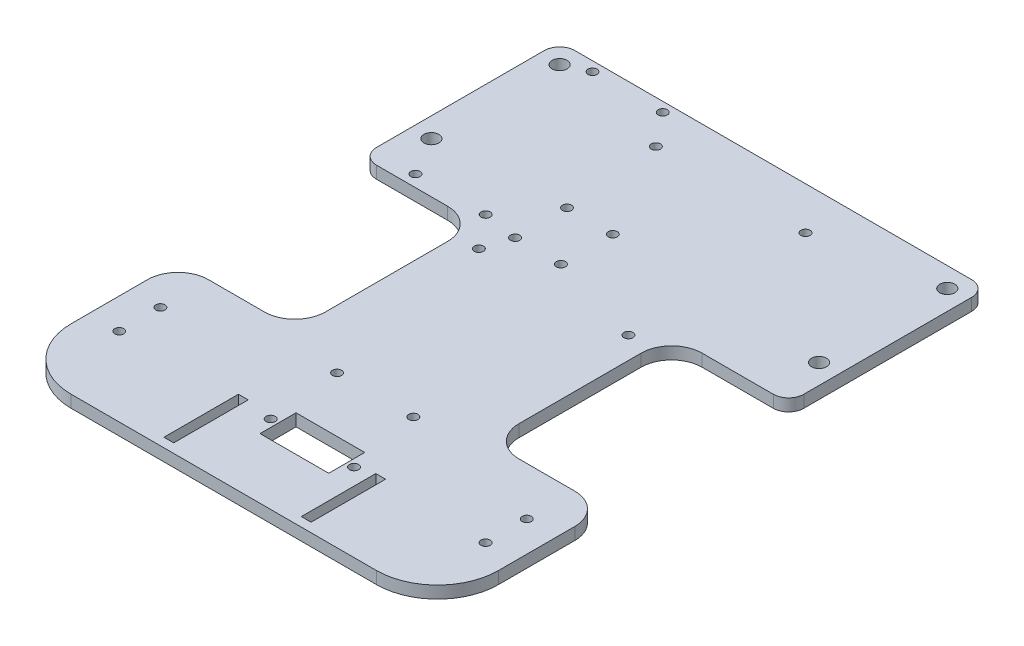
from build123d import *

# Parameters (mm, degrees)
BOSS_EXTRUDE1_DEPTH     = 4
SKETCH2_R               = 1.5
SKETCH2_R_2             = 2.45
SKETCH2_R_3             = 1.499994387
SKETCH2_R_4             = 1.499990712
SKETCH2_W               = 22.5
SKETCH2_H               = 11.8
SKETCH2_W_2             = 3.2
SKETCH2_H_2             = 24.403689174
SKETCH2_W_3             = 3.200000004
CUT_EXTRUDE1_DEPTH      = 1
CUT_EXTRUDE1_DEPTH_BACK = 5
CUT_EXTRUDE2_DEPTH      = 1
CUT_EXTRUDE2_DEPTH_BACK = 5
FILLET1_R               = 10
FILLET2_R               = 5


with BuildPart() as part:
    # Sketch1 → Boss-Extrude1 (new body)
    with BuildSketch(Plane(origin=(0, 0, 0), x_dir=(1, 0, 0), z_dir=(0, 1, 0))):
        with BuildLine():
            Line((-120, 0), (-135, 0))
            ThreePointArc((-135, 0), (-138.535533906, -1.464466094), (-140, -5))
            Line((-140, -5), (-140, -20))
            Line((-140, -20), (-140, -160))
            ThreePointArc((-140, -160), (-134.142135624, -174.142135624), (-120, -180))
            Line((-120, -180), (-20, -180))
            ThreePointArc((-20, -180), (-5.857864376, -174.142135624), (0, -160))
            Line((0, -160), (0, -20))
            Line((0, -20), (0, -5))
            ThreePointArc((0, -5), (-1.464466094, -1.464466094), (-5, 0))
            Line((-5, 0), (-20, 0))
            Line((-20, 0), (-120, 0))
        make_face()
    extrude(amount=BOSS_EXTRUDE1_DEPTH)

    # Sketch2 → Cut-Extrude1 (cut, two sides)
    with BuildSketch(Plane(origin=(0, 4, 0), x_dir=(1, 0, 0), z_dir=(0, 1, 0))) as cut_extrude1_sk:
        with Locations((-80.3, -154.329714663)):
            Circle(SKETCH2_R)
        with Locations((-53, -154.329714663)):
            Circle(SKETCH2_R)
        with Locations((-6.5, -6.5)):
            Circle(SKETCH2_R_2)
        with Locations((-6.5, -48.5)):
            Circle(SKETCH2_R_2)
        with Locations((-133.5, -48.5)):
            Circle(SKETCH2_R_2)
        with Locations((-133.5, -6.5)):
            Circle(SKETCH2_R_2)
        with Locations((-82.507017072, -130.388178469)):
            Circle(SKETCH2_R_3)
        with Locations((-57.507017072, -130.388178469)):
            Circle(SKETCH2_R_4)
        with Locations((-76.676059564, -45.89557362)):
            Circle(SKETCH2_R)
        with Locations((-91.676059564, -45.89557362)):
            Circle(SKETCH2_R)
        with Locations((-76.676059564, -62.89557362)):
            Circle(SKETCH2_R)
        with Locations((-91.676059564, -62.89557362)):
            Circle(SKETCH2_R)
        with Locations((-94.5, -71.948209631)):
            Circle(SKETCH2_R)
        with Locations((-45.5, -71.948209631)):
            Circle(SKETCH2_R)
        with Locations((-94.5, -13.948209631)):
            Circle(SKETCH2_R)
        with Locations((-45.5, -13.948209631)):
            Circle(SKETCH2_R)
        with Locations((-126.081815918, -3.135397693)):
            Circle(SKETCH2_R)
        with Locations((-103.081815918, -3.135397693)):
            Circle(SKETCH2_R)
        with Locations((-126.081815918, -61.135397693)):
            Circle(SKETCH2_R)
        with Locations((-103.081815918, -61.135397693)):
            Circle(SKETCH2_R)
        with Locations((-130, -140.75)):
            Circle(SKETCH2_R)
        with Locations((-130, -154.25)):
            Circle(SKETCH2_R)
        with Locations((-10, -154.25)):
            Circle(SKETCH2_R)
        with Locations((-10, -140.75)):
            Circle(SKETCH2_R)
        with Locations((-66.65, -154.329714663)):
            Rectangle(SKETCH2_W, SKETCH2_H)
        with Locations((-91, -164.798155413)):
            Rectangle(SKETCH2_W_2, SKETCH2_H_2)
        with Locations((-46, -164.798155413)):
            Rectangle(SKETCH2_W_3, SKETCH2_H_2)
    extrude(amount=CUT_EXTRUDE1_DEPTH, mode=Mode.SUBTRACT)
    extrude(cut_extrude1_sk.sketch, amount=-CUT_EXTRUDE1_DEPTH_BACK, mode=Mode.SUBTRACT)

    # Sketch3 → Cut-Extrude2 (cut, two sides)
    with BuildSketch(Plane(origin=(0, 0, 0), x_dir=(-1, 0, 0), z_dir=(0, -1, 0))) as cut_extrude2_sk:
        with BuildLine():
            Line((0, -65), (28.307017072, -65))
            ThreePointArc((28.307017072, -65), (35.378084884, -67.928932188), (38.307017072, -75))
            Line((38.307017072, -75), (38.307017072, -115))
            ThreePointArc((38.307017072, -115), (35.378084884, -122.071067812), (28.307017072, -125))
            Line((28.307017072, -125), (0, -125))
            Line((0, -125), (0, -65))
        make_face()
        with BuildLine():
            Line((140, -65), (140, -125))
            Line((140, -125), (111.692982928, -125))
            ThreePointArc((111.692982928, -125), (104.621915116, -122.071067812), (101.692982928, -115))
            Line((101.692982928, -115), (101.692982928, -75))
            ThreePointArc((101.692982928, -75), (104.621915116, -67.928932188), (111.692982928, -65))
            Line((111.692982928, -65), (140, -65))
        make_face()
    extrude(amount=CUT_EXTRUDE2_DEPTH, mode=Mode.SUBTRACT)
    extrude(cut_extrude2_sk.sketch, amount=-CUT_EXTRUDE2_DEPTH_BACK, mode=Mode.SUBTRACT)

    # Fillet1
    fillet1_edges = [part.edges().sort_by_distance(p)[0] for p in [
        (0, 2, 125),
        (-140, 2, 125),
    ]]
    fillet(fillet1_edges, radius=FILLET1_R)

    # Fillet2
    fillet2_edges = [part.edges().sort_by_distance(p)[0] for p in [
        (0, 2, 65),
        (-140, 2, 65),
    ]]
    fillet(fillet2_edges, radius=FILLET2_R)


solid = part.part
